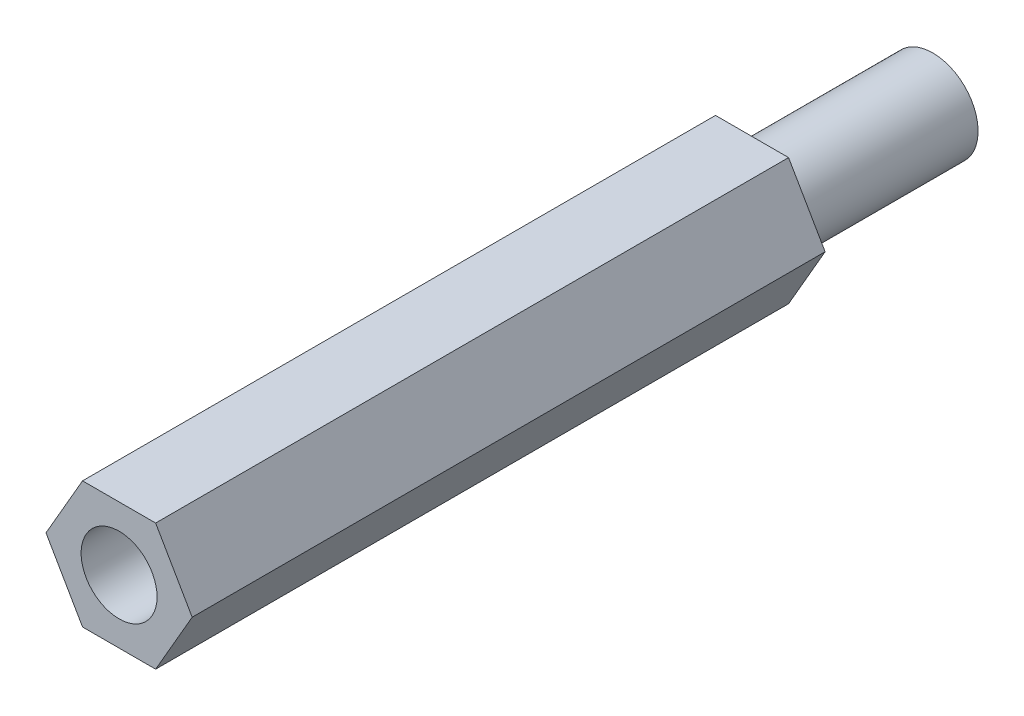
from build123d import *

# Parameters (mm, degrees)
EXTRUDE_1_DEPTH           = 35
SKETCH_4_R                = 2.5
EXTRUDE_2_DEPTH           = 10
M5X0_8_TAPPED_HOLE1_D     = 4.2
M5X0_8_TAPPED_HOLE1_DEPTH = 14
M5X0_8_TAPPED_HOLE1_TIP   = 1.2618073


with BuildPart() as part:
    # 草圖1 → 填料-伸長1 (new body)
    with BuildSketch(Plane.XY):
        Polygon((-2.020725942, 3.5), (-4.041451884, 0), (-2.020725942, -3.5), (2.020725942, -3.5), (4.041451884, 0), (2.020725942, 3.5), align=None)
    extrude(amount=EXTRUDE_1_DEPTH)

    # 草圖4 → 填料-伸長2 (add)
    with BuildSketch(Plane(origin=(0, 0, 0), x_dir=(-1, 0, 0), z_dir=(0, 0, -1))):
        Circle(SKETCH_4_R)
    extrude(amount=EXTRUDE_2_DEPTH)

    # M5x0.8 Tapped Hole1
    with Locations(Plane.XY.offset(35)):
        with Locations((0, 0)):
            Hole(M5X0_8_TAPPED_HOLE1_D / 2, depth=M5X0_8_TAPPED_HOLE1_DEPTH)
            with Locations((0, 0, -(M5X0_8_TAPPED_HOLE1_DEPTH + M5X0_8_TAPPED_HOLE1_TIP / 2))):  # 118° drill point
                Cone(0, M5X0_8_TAPPED_HOLE1_D / 2, M5X0_8_TAPPED_HOLE1_TIP, mode=Mode.SUBTRACT)


solid = part.part
